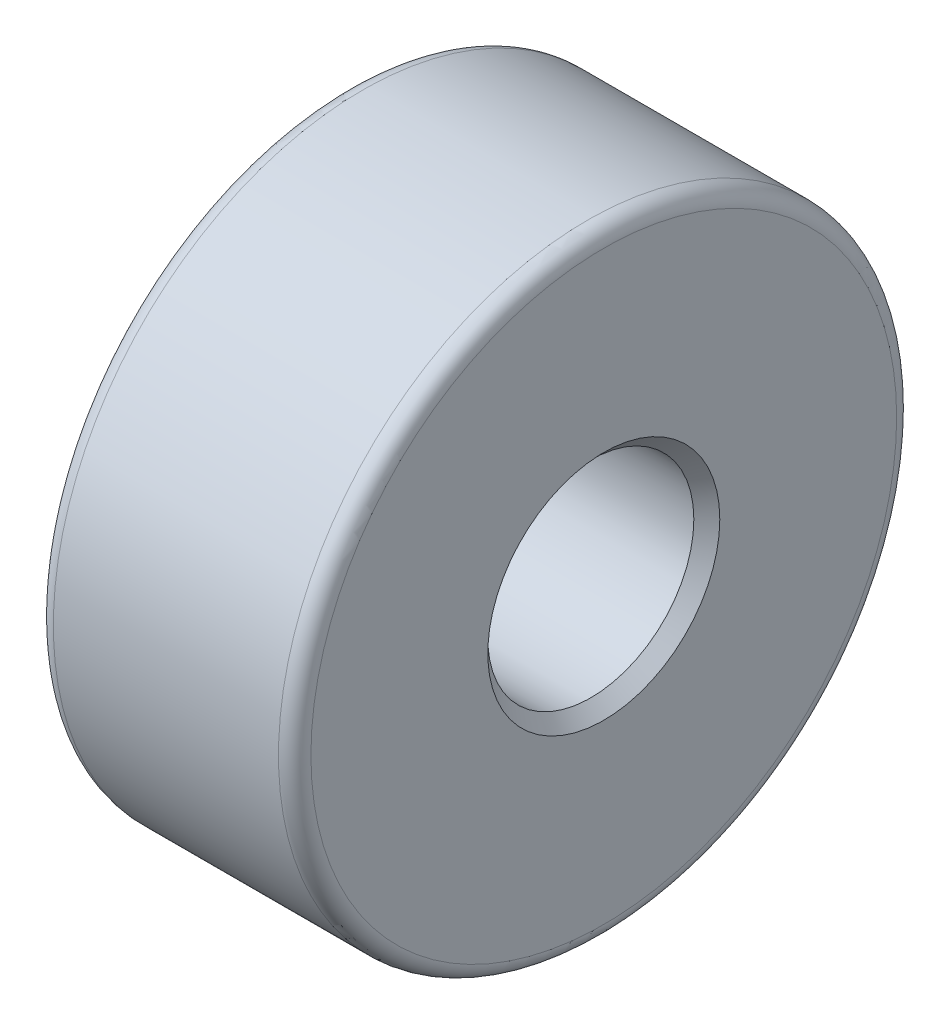
from build123d import *

# Parameters (mm, degrees)
SKETCH1_R           = 4.7625
SKETCH1_R_2         = 1.5875
BOSS_EXTRUDE1_DEPTH = 3.96875
CHAMFER1_SIZE       = 0.2
FILLET1_R           = 0.25


with BuildPart() as part:
    # Sketch1 → Boss-Extrude1 (new body)
    with BuildSketch(Plane(origin=(0, 0, 0), x_dir=(0, 0, -1), z_dir=(1, 0, 0))):
        Circle(SKETCH1_R)
        Circle(SKETCH1_R_2, mode=Mode.SUBTRACT)
    extrude(amount=BOSS_EXTRUDE1_DEPTH)

    # Chamfer1
    chamfer1_edges = [part.edges().sort_by_distance(p)[0] for p in [
        (0, 0, 1.5875),
        (3.96875, 0, 1.5875),
    ]]
    chamfer(chamfer1_edges, length=CHAMFER1_SIZE)

    # Fillet1
    fillet1_edges = [part.edges().sort_by_distance(p)[0] for p in [
        (0, 0, 4.7625),
        (3.96875, 0, 4.7625),
    ]]
    fillet(fillet1_edges, radius=FILLET1_R)


solid = part.part
